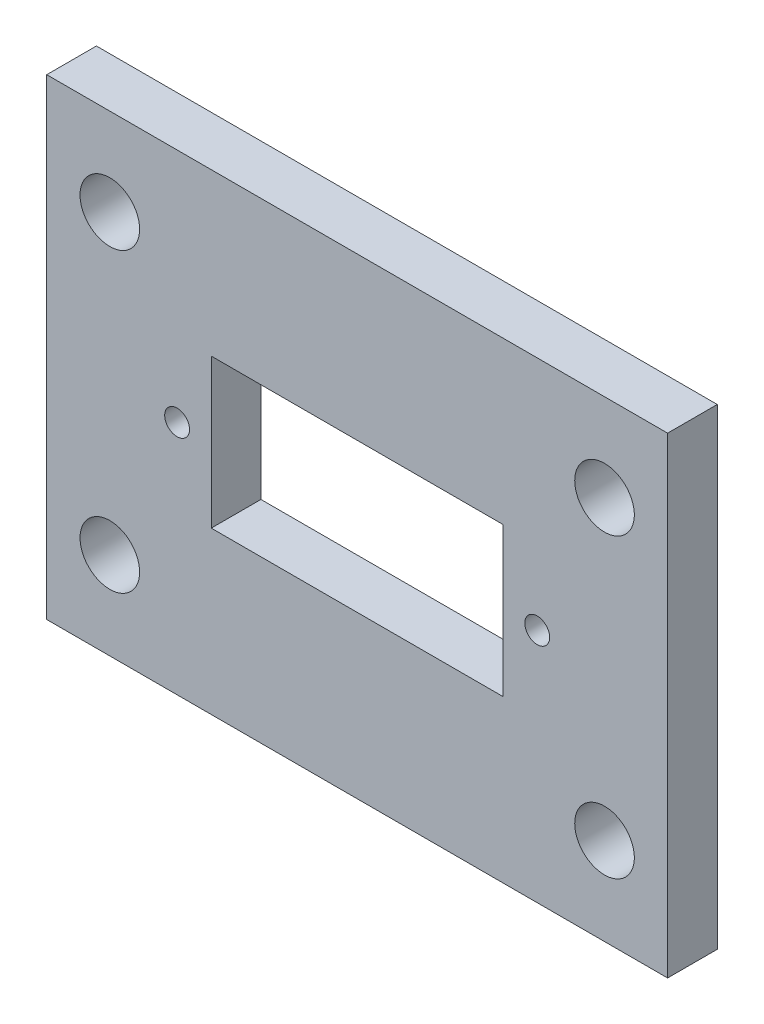
from build123d import *

# Parameters (mm, degrees)
SKETCH1_W           = 50
SKETCH1_H           = 38
SKETCH1_R           = 2.4
SKETCH1_W_2         = 23.5
SKETCH1_H_2         = 12
BOSS_EXTRUDE1_DEPTH = 4
CUT_EXTRUDE1_REACH  = 6
SKETCH2_R           = 1


with BuildPart() as part:
    # Sketch1 → Boss-Extrude1 (new body)
    with BuildSketch(Plane.XY):
        with Locations((0, -19)):
            Rectangle(SKETCH1_W, SKETCH1_H)
        with Locations((-19.92, -7.045)):
            Circle(SKETCH1_R, mode=Mode.SUBTRACT)
        with Locations((-19.92, -30.955)):
            Circle(SKETCH1_R, mode=Mode.SUBTRACT)
        with Locations((19.92, -30.955)):
            Circle(SKETCH1_R, mode=Mode.SUBTRACT)
        with Locations((19.92, -7.045)):
            Circle(SKETCH1_R, mode=Mode.SUBTRACT)
        with Locations((0, -19)):
            Rectangle(SKETCH1_W_2, SKETCH1_H_2, mode=Mode.SUBTRACT)
    extrude(amount=BOSS_EXTRUDE1_DEPTH)

    # Sketch2 → Cut-Extrude1 (cut, up to next)
    with BuildSketch(Plane.XY.offset(4), mode=Mode.PRIVATE) as cut_extrude1_sk1:
        with Locations((-14.5, -19)):
            Circle(SKETCH2_R)
    cut_extrude1_tool1 = extrude(cut_extrude1_sk1.sketch, amount=-CUT_EXTRUDE1_REACH, mode=Mode.PRIVATE) & part.part
    add(cut_extrude1_tool1.solids().sort_by_distance((-14.5, -19, 4))[0], mode=Mode.SUBTRACT)
    # Sketch2 → Cut-Extrude1 (cut, up to next)
    with BuildSketch(Plane.XY.offset(4), mode=Mode.PRIVATE) as cut_extrude1_sk2:
        with Locations((14.5, -19)):
            Circle(SKETCH2_R)
    cut_extrude1_tool2 = extrude(cut_extrude1_sk2.sketch, amount=-CUT_EXTRUDE1_REACH, mode=Mode.PRIVATE) & part.part
    add(cut_extrude1_tool2.solids().sort_by_distance((14.5, -19, 4))[0], mode=Mode.SUBTRACT)


solid = part.part
